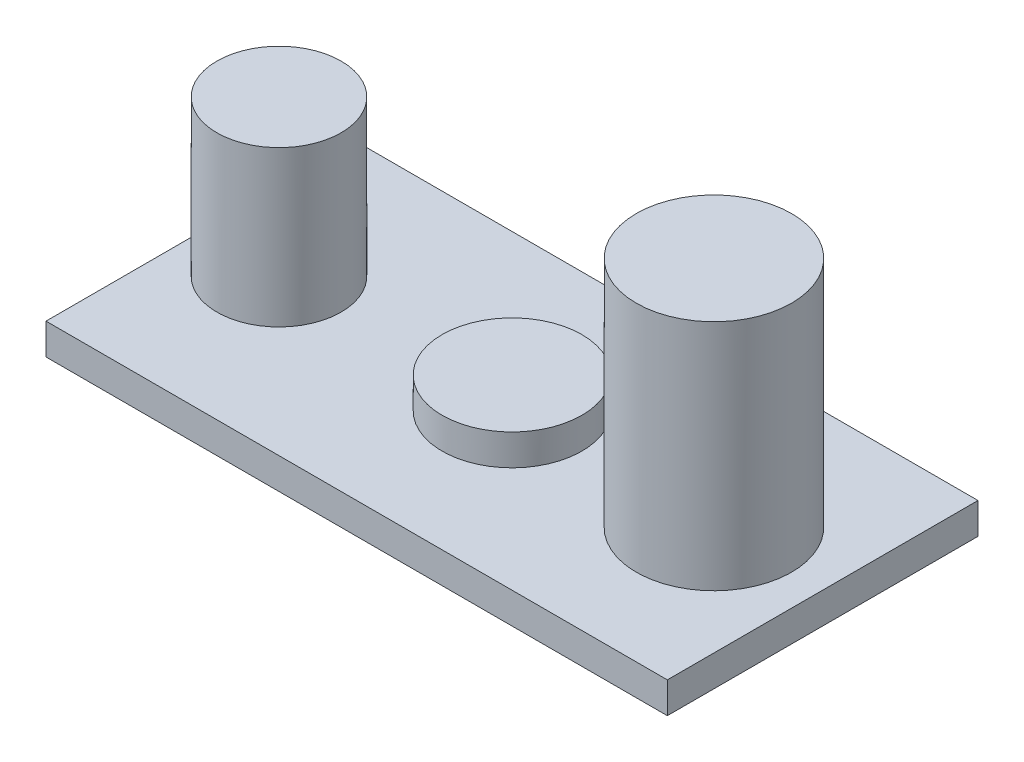
from build123d import *

# Parameters (mm, degrees)
SKETCH1_W           = 100
SKETCH1_H           = 50
BOSS_EXTRUDE1_DEPTH = 5
SKETCH3_R           = 10
BOSS_EXTRUDE2_DEPTH = 25
SKETCH4_R           = 11.25
BOSS_EXTRUDE3_DEPTH = 5
SKETCH5_R           = 12.5
BOSS_EXTRUDE4_DEPTH = 37.5


with BuildPart() as part:
    # Sketch1 → Boss-Extrude1 (new body)
    with BuildSketch(Plane(origin=(0, 0, 0), x_dir=(1, 0, 0), z_dir=(0, 1, 0))):
        with Locations((50, 25)):
            Rectangle(SKETCH1_W, SKETCH1_H)
    extrude(amount=BOSS_EXTRUDE1_DEPTH)

    # Sketch3 → Boss-Extrude2 (add)
    with BuildSketch(Plane(origin=(0, 5, 0), x_dir=(1, 0, 0), z_dir=(0, 1, 0))):
        with Locations((12.5, 25)):
            Circle(SKETCH3_R)
    extrude(amount=BOSS_EXTRUDE2_DEPTH)

    # Sketch4 → Boss-Extrude3 (add)
    with BuildSketch(Plane(origin=(0, 5, 0), x_dir=(1, 0, 0), z_dir=(0, 1, 0))):
        with Locations((50, 25)):
            Circle(SKETCH4_R)
    extrude(amount=BOSS_EXTRUDE3_DEPTH)

    # Sketch5 → Boss-Extrude4 (add)
    with BuildSketch(Plane(origin=(0, 5, 0), x_dir=(1, 0, 0), z_dir=(0, 1, 0))):
        with Locations((82.5, 25)):
            Circle(SKETCH5_R)
    extrude(amount=BOSS_EXTRUDE4_DEPTH)


solid = part.part
